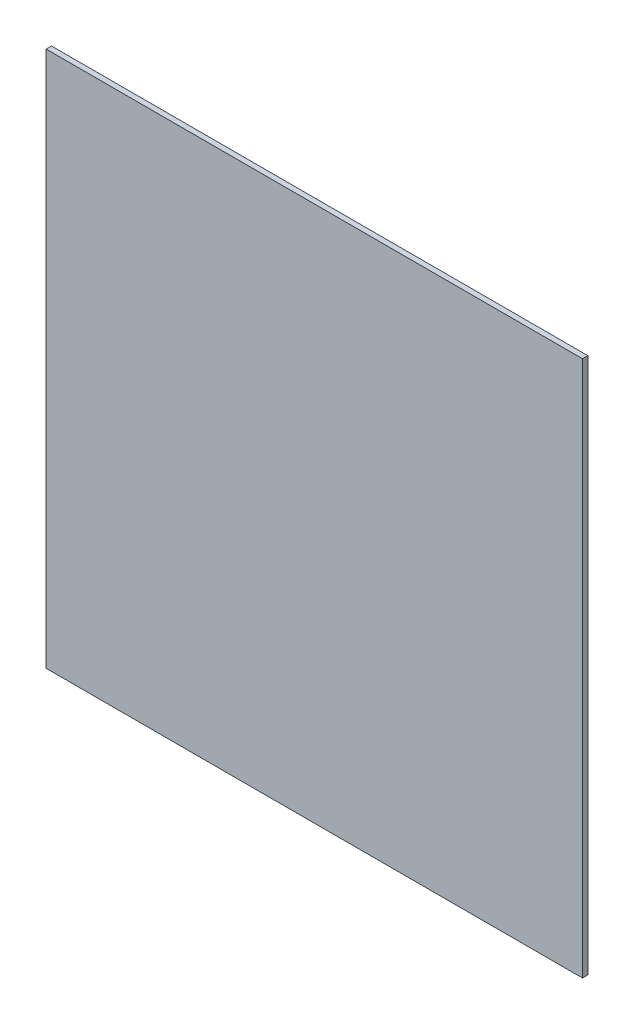
from build123d import *

# Parameters (mm, degrees)
ESQUISSE1_W        = 300
ESQUISSE1_H        = 300
BOSS_EXTRU_1_DEPTH = 3


with BuildPart() as part:
    # Esquisse1 → Boss.-Extru.1 (new body)
    with BuildSketch(Plane.XY):
        with Locations((79.97582642, -51.656229143)):
            Rectangle(ESQUISSE1_W, ESQUISSE1_H)
    extrude(amount=BOSS_EXTRU_1_DEPTH)


solid = part.part
